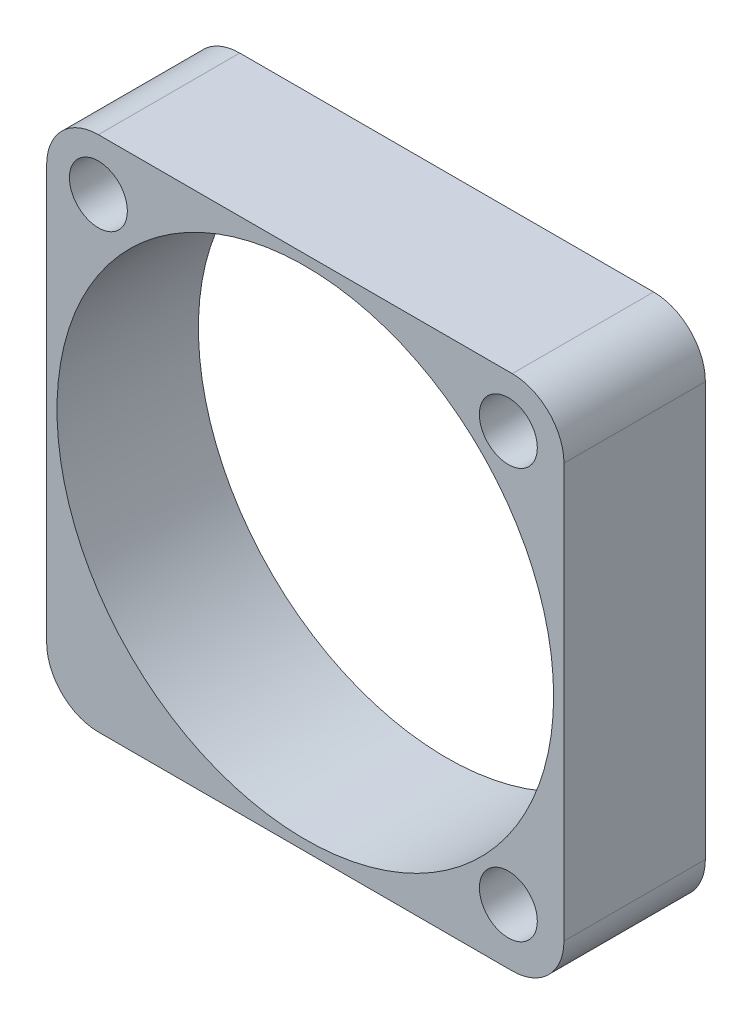
from build123d import *

# Parameters (mm, degrees)
SKETCH1_W           = 25
SKETCH1_H           = 25
BOSS_EXTRUDE1_DEPTH = 6.8325
SKETCH2_R           = 12
CUT_EXTRUDE1_DEPTH  = 7.8325
SKETCH3_R           = 1.4
CUT_EXTRUDE2_DEPTH  = 7.8325
FILLET1_R           = 2.5


with BuildPart() as part:
    # Sketch1 → Boss-Extrude1 (new body)
    with BuildSketch(Plane.XY):
        with Locations((12.5, 12.5)):
            Rectangle(SKETCH1_W, SKETCH1_H)
    extrude(amount=BOSS_EXTRUDE1_DEPTH)

    # Sketch2 → Cut-Extrude1 (cut, through all)
    with BuildSketch(Plane.XY.offset(6.8325)):
        with Locations((12.5, 12.5)):
            Circle(SKETCH2_R)
    extrude(amount=-CUT_EXTRUDE1_DEPTH, mode=Mode.SUBTRACT)

    # Sketch3 → Cut-Extrude2 (cut, through all)
    with BuildSketch(Plane.XY.offset(6.8325)):
        with Locations((2.5, 22.5)):
            Circle(SKETCH3_R)
        with Locations((22.312, 22.5)):
            Circle(SKETCH3_R)
        with Locations((22.312, 2.688)):
            Circle(SKETCH3_R)
    extrude(amount=-CUT_EXTRUDE2_DEPTH, mode=Mode.SUBTRACT)

    # Fillet1
    fillet1_edges = [part.edges().sort_by_distance(p)[0] for p in [
        (0, 25, 3.41625),
        (25, 25, 3.41625),
        (25, 0, 3.41625),
        (0, 0, 3.41625),
    ]]
    fillet(fillet1_edges, radius=FILLET1_R)


solid = part.part
